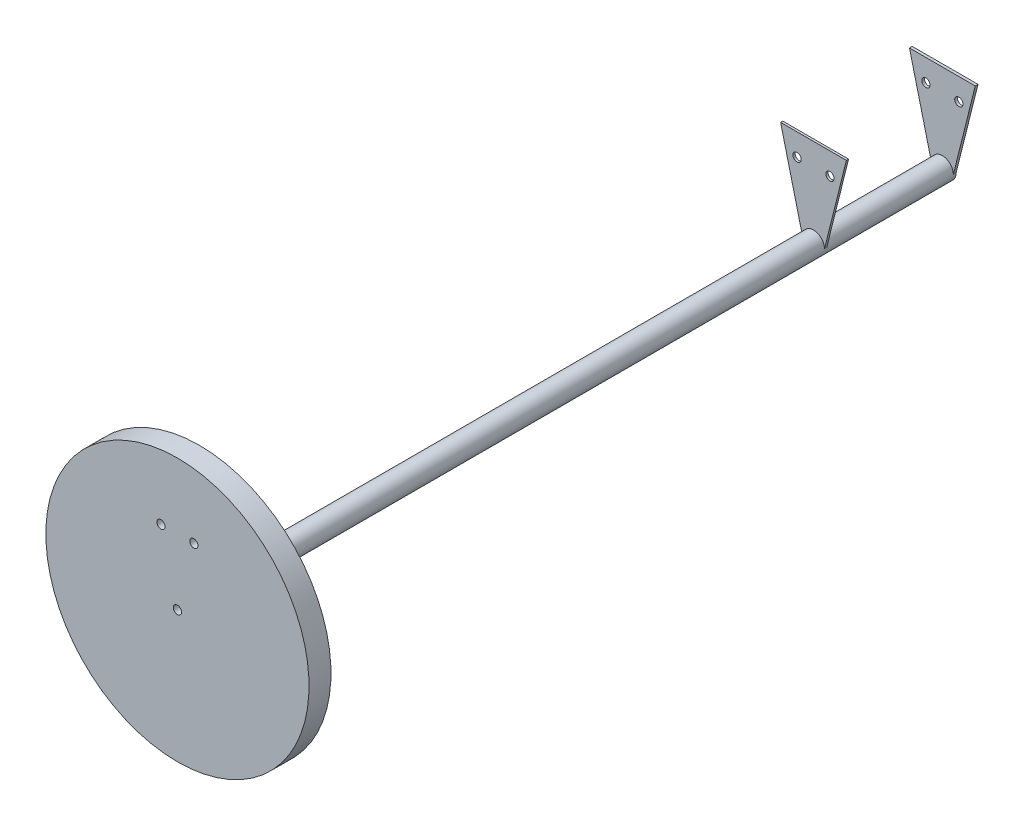
from build123d import *

# Parameters (mm, degrees)
END_TAB_1_DEPTH     = 3.175
SKETCH4_R           = 4.7625
END_TAB_1_CUT_DEPTH = 890
SKETCH5_R           = 4.7625
BOSS_EXTRUDE1_DEPTH = 2.54


with BuildPart() as part:
    # Sketch1 → OAL Revolve (revolve)
    with BuildSketch(Plane(origin=(0, 0, 0), x_dir=(0, 0, -1), z_dir=(1, 0, 0))):
        Polygon((-444.5, 0), (444.5, 0), (444.5, 12.7), (-419.1, 12.7), (-419.1, 152.4), (-444.5, 152.4), align=None)
    revolve(axis=Axis((0, 0, 444.5), (0, 0, -1)))

    # Sketch3 → End Tab 1 (add)
    with BuildSketch(Plane(origin=(0, 0, -444.5), x_dir=(-1, 0, 0), z_dir=(0, 0, -1))):
        Polygon((12.7, 0), (-12.7, 0), (-38.1, 101.6), (38.1, 101.6), align=None)
    extrude(amount=-END_TAB_1_DEPTH)

    # Sketch4 → End Tab 1 Cut (cut, through all)
    with BuildSketch(Plane(origin=(0, 0, -444.5), x_dir=(-1, 0, 0), z_dir=(0, 0, -1))):
        with Locations((-19.05, 76.2)):
            Circle(SKETCH4_R)
        with Locations((19.05, 76.2)):
            Circle(SKETCH4_R)
        Circle(SKETCH4_R)
    extrude(amount=-END_TAB_1_CUT_DEPTH, mode=Mode.SUBTRACT)

    # Sketch5 → Boss-Extrude1 (add)
    with BuildSketch(Plane(origin=(0, 0, -292.1), x_dir=(-1, 0, 0), z_dir=(0, 0, -1))):
        with BuildLine():
            Line((12.7, 0), (38.1, 101.6))
            Line((38.1, 101.6), (-38.1, 101.6))
            Line((-38.1, 101.6), (-12.7, 0))
            ThreePointArc((-12.7, 0), (0, 12.7), (12.7, 0))
        make_face()
        with Locations((19.05, 76.2)):
            Circle(SKETCH5_R, mode=Mode.SUBTRACT)
        with Locations((-19.05, 76.2)):
            Circle(SKETCH5_R, mode=Mode.SUBTRACT)
    extrude(amount=BOSS_EXTRUDE1_DEPTH)


solid = part.part
